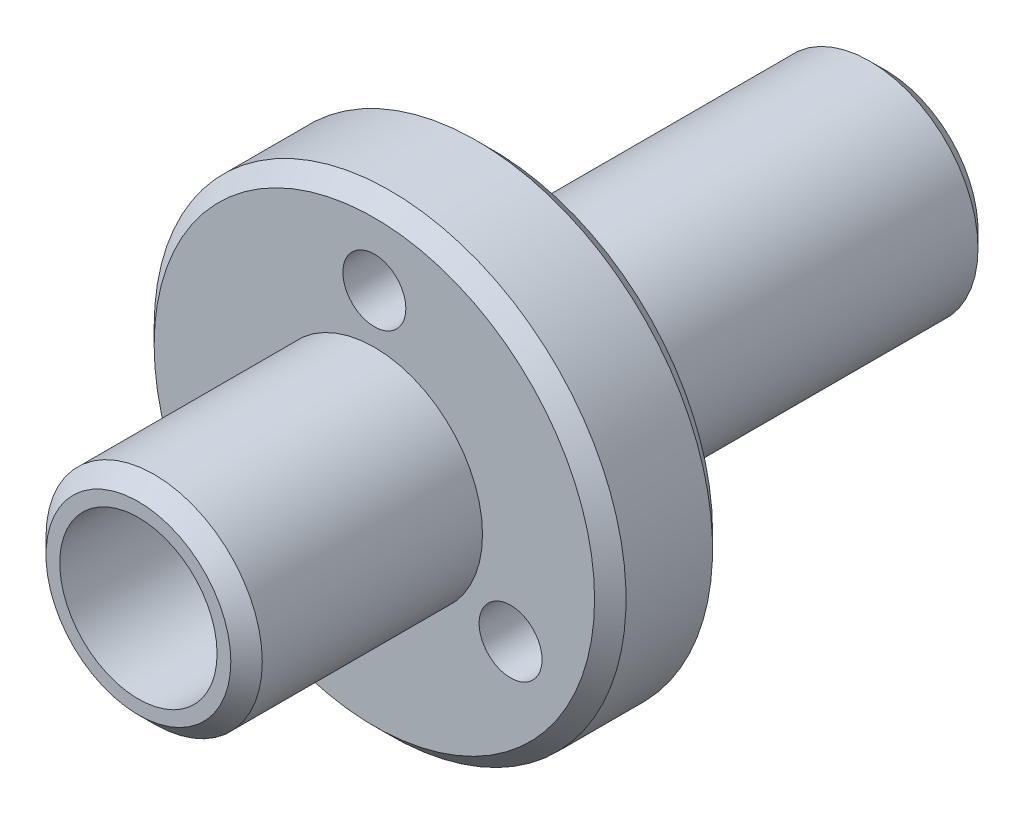
from build123d import *

# Parameters (mm, degrees)
SKETCH1_R             = 2.75
BOSS_EXTRUDE1_DEPTH   = 6
SKETCH3_R             = 6
BOSS_EXTRUDE2_DEPTH   = 3
SKETCH4_R             = 2.75
BOSS_EXTRUDE3_DEPTH   = 10
M2X0_4_TAPPED_HOLE1_D = 1.6
CHAMFER1_SIZE         = 0.4
SKETCH7_R             = 2
CUT_EXTRUDE1_DEPTH    = 20


with BuildPart() as part:
    # Sketch1 → Boss-Extrude1 (new body)
    with BuildSketch(Plane.XY):
        with Locations((-27.5, 59.99791663)):
            Circle(SKETCH1_R)
    extrude(amount=-BOSS_EXTRUDE1_DEPTH)

    # Sketch3 → Boss-Extrude2 (add)
    with BuildSketch(Plane(origin=(0, 0, -6), x_dir=(-1, 0, 0), z_dir=(0, 0, -1))):
        with Locations((27.5, 59.99791663)):
            Circle(SKETCH3_R)
    extrude(amount=BOSS_EXTRUDE2_DEPTH)

    # Sketch4 → Boss-Extrude3 (add)
    with BuildSketch(Plane(origin=(0, 0, -9), x_dir=(-1, 0, 0), z_dir=(0, 0, -1))):
        with Locations((27.5, 59.99791663)):
            Circle(SKETCH4_R)
    extrude(amount=BOSS_EXTRUDE3_DEPTH)

    # M2x0.4 Tapped Hole1 (through all)
    with Locations(Plane.XY.offset(-6)):
        with Locations((-24.035898385, 57.99791663), (-30.964101615, 57.99791663), (-27.5, 63.99791663)):
            Hole(M2X0_4_TAPPED_HOLE1_D / 2)

    # Chamfer1
    chamfer1_edges = [part.edges().sort_by_distance(p)[0] for p in [
        (-24.75, 59.99791663, -19),
        (-30.25, 59.99791663, 0),
        (-21.5, 59.99791663, -6),
        (-21.5, 59.99791663, -9),
    ]]
    chamfer(chamfer1_edges, length=CHAMFER1_SIZE)

    # Sketch7 → Cut-Extrude1 (cut, through all)
    with BuildSketch(Plane.XY):
        with Locations((-27.5, 59.99791663)):
            Circle(SKETCH7_R)
    extrude(amount=-CUT_EXTRUDE1_DEPTH, mode=Mode.SUBTRACT)


solid = part.part
